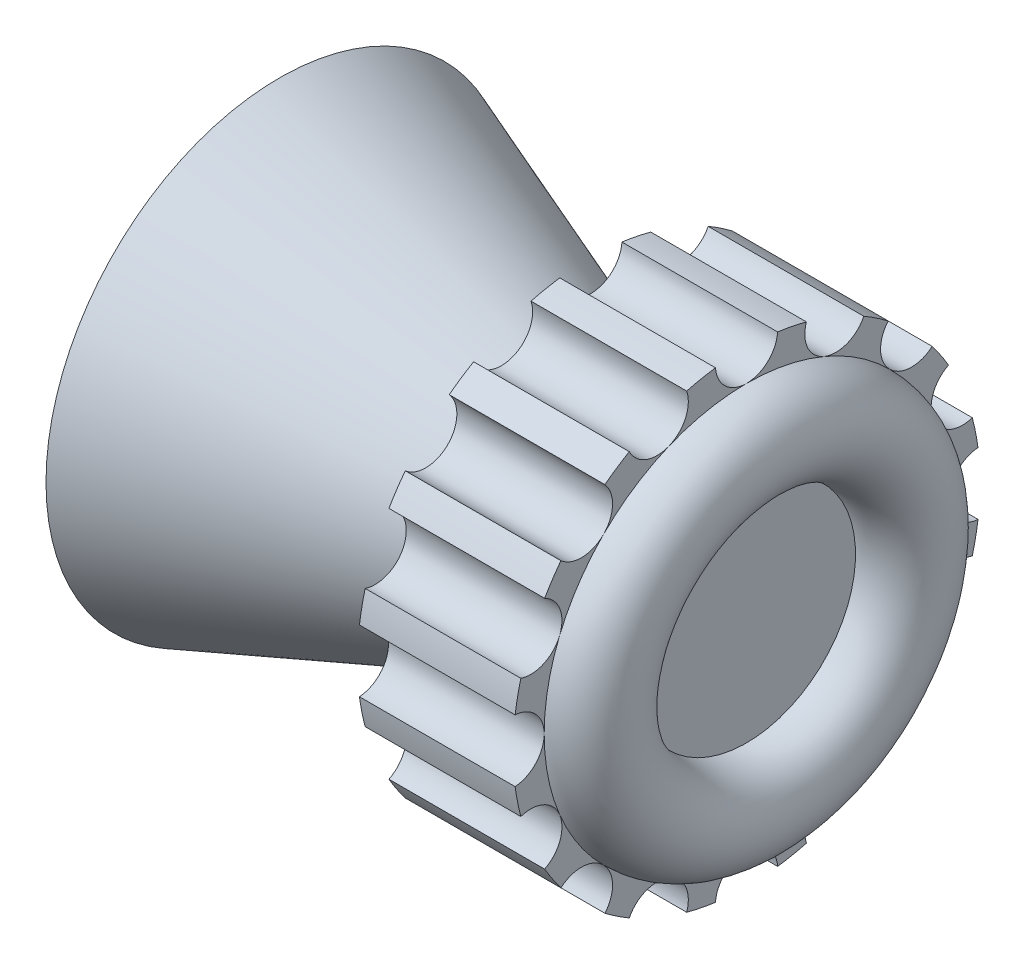
from build123d import *

# Parameters (mm, degrees)
BOSS_EXTRUDE1_DEPTH = 7
CUT_EXTRUDE1_DEPTH  = 5


with BuildPart() as part:
    # Sketch1 → Revolve1 (revolve)
    with BuildSketch(Plane.XY):
        with BuildLine():
            Line((-4.75, 5.5), (-4.75, 7.5))
            Line((-4.75, 7.5), (5.25, 3.755937126))
            Line((5.25, 3.755937126), (5.25, 7.5))
            Line((5.25, 7.5), (10.25, 7.5))
            Line((10.25, 7.5), (10.25, 6.5))
            ThreePointArc((10.25, 6.5), (11.75, 5), (10.25, 3.5))
            Line((10.25, 3.5), (10.25, 2.5))
            Line((10.25, 2.5), (10.25, 0))
            Line((10.25, 0), (7.25, 0))
            Line((7.25, 0), (7.25, 2))
            Line((7.25, 2), (0.25, 2))
            Line((0.25, 2), (0.25, 3.75))
            Line((0.25, 3.75), (-4.75, 5.5))
        make_face()
    revolve(axis=Axis((-16.375, 0, 0), (1, 0, 0)))

    # Sketch2 → Boss-Extrude1 (add)
    with BuildSketch(Plane.ZY.offset(-0.25)):
        with BuildLine():
            Line((1.1, 1.670329309), (1.1, -1.670329309))
            ThreePointArc((1.1, -1.670329309), (2, 0), (1.1, 1.670329309))
        make_face()
    extrude(amount=-BOSS_EXTRUDE1_DEPTH)

    # Sketch3 → Cut-Extrude1 (cut)
    with BuildSketch(Plane(origin=(10.25, 0, 0), x_dir=(0, 0, -1), z_dir=(1, 0, 0))):
        with BuildLine():
            ThreePointArc((-4.550626724, -5.96169409), (-4.303857188, -5.269948975), (-4.596194072, -4.596194084))
            ThreePointArc((-4.596194072, -4.596194084), (-5.269948967, -4.303857188), (-5.96169409, -4.550626724))
            ThreePointArc((-5.96169409, -4.550626724), (-5.303300859, -5.303300859), (-4.550626724, -5.96169409))
        make_face()
        with BuildLine():
            ThreePointArc((-1.922789333, -7.249336603), (-1.959523399, -6.515812848), (-2.487442279, -6.005216974))
            ThreePointArc((-2.487442279, -6.005216974), (-3.221783135, -5.992967721), (-3.766437695, -6.485672447))
            ThreePointArc((-3.766437695, -6.485672447), (-2.870125743, -6.929096494), (-1.922789333, -7.249336603))
        make_face()
        with BuildLine():
            ThreePointArc((0.997775303, -7.433333333), (0.683130051, -6.769703257), (0, -6.5))
            ThreePointArc((0, -6.5), (-0.683130051, -6.769703257), (-0.997775303, -7.433333333))
            ThreePointArc((-0.997775303, -7.433333333), (0, -7.5), (0.997775303, -7.433333333))
        make_face()
        with BuildLine():
            ThreePointArc((3.766437695, -6.485672447), (3.221782808, -5.992967599), (2.487441634, -6.005217241))
            ThreePointArc((2.487441634, -6.005217241), (1.959523255, -6.515813166), (1.922789333, -7.249336603))
            ThreePointArc((1.922789333, -7.249336603), (2.870125743, -6.929096494), (3.766437695, -6.485672447))
        make_face()
        with BuildLine():
            ThreePointArc((5.96169409, -4.550626724), (5.269948971, -4.303857188), (4.596194077, -4.596194078))
            ThreePointArc((4.596194077, -4.596194078), (4.303857188, -5.269948971), (4.550626724, -5.96169409))
            ThreePointArc((4.550626724, -5.96169409), (5.303300859, -5.303300859), (5.96169409, -4.550626724))
        make_face()
        with BuildLine():
            ThreePointArc((7.249336603, -1.922789333), (6.51581242, -1.959523594), (6.005216614, -2.487443148))
            ThreePointArc((6.005216614, -2.487443148), (5.992967887, -3.221783575), (6.485672447, -3.766437695))
            ThreePointArc((6.485672447, -3.766437695), (6.929096494, -2.870125743), (7.249336603, -1.922789333))
        make_face()
        with BuildLine():
            ThreePointArc((6.485672447, 3.766437695), (5.992967893, 3.221783593), (6.0052166, 2.487443183))
            ThreePointArc((6.0052166, 2.487443183), (6.515812403, 1.959523601), (7.249336603, 1.922789333))
            ThreePointArc((7.249336603, 1.922789333), (6.929096494, 2.870125743), (6.485672447, 3.766437695))
        make_face()
        with BuildLine():
            ThreePointArc((7.433333333, 0.997775303), (6.769703257, 0.683130051), (6.5, 0))
            ThreePointArc((6.5, 0), (6.769703257, -0.683130051), (7.433333333, -0.997775303))
            ThreePointArc((7.433333333, -0.997775303), (7.483314774, -0.5), (7.5, 0))
            ThreePointArc((7.5, 0), (7.483314774, 0.5), (7.433333333, 0.997775303))
        make_face()
        with BuildLine():
            ThreePointArc((4.550626724, 5.96169409), (4.303857188, 5.269948971), (4.596194078, 4.596194078))
            ThreePointArc((4.596194078, 4.596194078), (5.269948971, 4.303857188), (5.96169409, 4.550626724))
            ThreePointArc((5.96169409, 4.550626724), (5.303300859, 5.303300859), (4.550626724, 5.96169409))
        make_face()
        with BuildLine():
            ThreePointArc((1.922789333, 7.249336603), (1.959523233, 6.515813213), (2.487441538, 6.005217281))
            ThreePointArc((2.487441538, 6.005217281), (3.221782759, 5.99296758), (3.766437695, 6.485672447))
            ThreePointArc((3.766437695, 6.485672447), (2.870125743, 6.929096494), (1.922789333, 7.249336603))
        make_face()
        with BuildLine():
            ThreePointArc((-0.997775303, 7.433333333), (-0.683130051, 6.769703257), (0, 6.5))
            ThreePointArc((0, 6.5), (0.683130051, 6.769703257), (0.997775303, 7.433333333))
            ThreePointArc((0.997775303, 7.433333333), (0, 7.5), (-0.997775303, 7.433333333))
        make_face()
        with BuildLine():
            ThreePointArc((-6.005216971, -2.487442288), (-6.515812844, -1.959523401), (-7.249336603, -1.922789333))
            ThreePointArc((-7.249336603, -1.922789333), (-6.929096494, -2.870125743), (-6.485672447, -3.766437695))
            ThreePointArc((-6.485672447, -3.766437695), (-5.992967723, -3.221783139), (-6.005216971, -2.487442288))
        make_face()
        with BuildLine():
            ThreePointArc((-7.433333333, 0.997775303), (-7.5, 0), (-7.433333333, -0.997775303))
            ThreePointArc((-7.433333333, -0.997775303), (-6.769703257, -0.683130051), (-6.5, 0))
            ThreePointArc((-6.5, 0), (-6.769703257, 0.683130051), (-7.433333333, 0.997775303))
        make_face()
        with BuildLine():
            ThreePointArc((-7.249336603, 1.922789333), (-6.515812818, 1.959523413), (-6.005216949, 2.487442341))
            ThreePointArc((-6.005216949, 2.487442341), (-5.992967733, 3.221783166), (-6.485672447, 3.766437695))
            ThreePointArc((-6.485672447, 3.766437695), (-6.929096494, 2.870125743), (-7.249336603, 1.922789333))
        make_face()
        with BuildLine():
            ThreePointArc((-5.96169409, 4.550626724), (-5.269948974, 4.303857188), (-4.596194082, 4.596194074))
            ThreePointArc((-4.596194082, 4.596194074), (-4.303857188, 5.269948968), (-4.550626724, 5.96169409))
            ThreePointArc((-4.550626724, 5.96169409), (-5.303300859, 5.303300859), (-5.96169409, 4.550626724))
        make_face()
        with BuildLine():
            ThreePointArc((-3.766437695, 6.485672447), (-3.221783319, 5.992967791), (-2.487442643, 6.005216823))
            ThreePointArc((-2.487442643, 6.005216823), (-1.959523481, 6.515812669), (-1.922789333, 7.249336603))
            ThreePointArc((-1.922789333, 7.249336603), (-2.870125743, 6.929096494), (-3.766437695, 6.485672447))
        make_face()
    extrude(amount=-CUT_EXTRUDE1_DEPTH, mode=Mode.SUBTRACT)


solid = part.part
